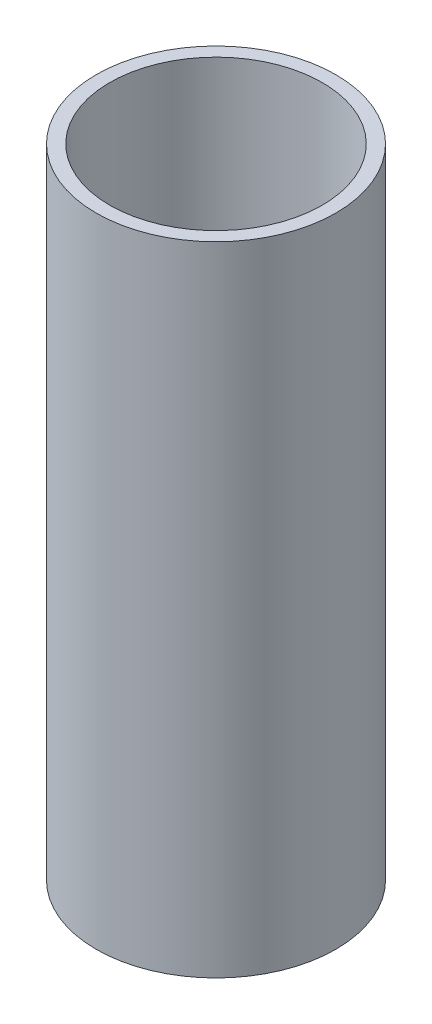
from build123d import *

# Parameters (mm, degrees)
SKETCH1_R      = 3.5814
SKETCH1_R_2    = 3.175
EXTRUDE1_DEPTH = 19.05


with BuildPart() as part:
    # Sketch1 → Extrude1 (new body)
    with BuildSketch(Plane(origin=(0, 0, 0), x_dir=(1, 0, 0), z_dir=(0, 1, 0))):
        Circle(SKETCH1_R)
        Circle(SKETCH1_R_2, mode=Mode.SUBTRACT)
    extrude(amount=EXTRUDE1_DEPTH)


solid = part.part
